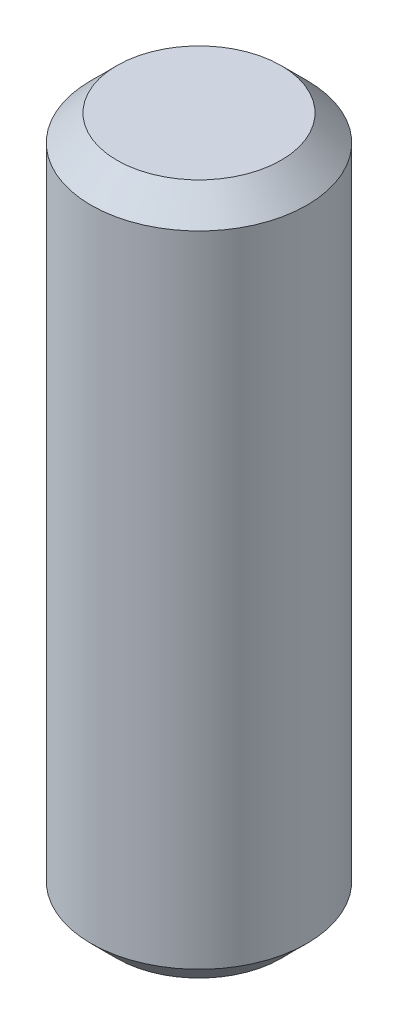
from build123d import *

# Parameters (mm, degrees)
SKETCH2_R           = 6.35
BOSS_EXTRUDE1_DEPTH = 40.64
CHAMFER1_SIZE       = 1.524


with BuildPart() as part:
    # Sketch2 → Boss-Extrude1 (new body)
    with BuildSketch(Plane(origin=(0, 0, 0), x_dir=(1, 0, 0), z_dir=(0, 1, 0))):
        Circle(SKETCH2_R)
    extrude(amount=BOSS_EXTRUDE1_DEPTH)

    # Chamfer1
    chamfer1_edges = [part.edges().sort_by_distance(p)[0] for p in [
        (-6.35, 0, 0),
        (-6.35, 40.64, 0),
    ]]
    chamfer(chamfer1_edges, length=CHAMFER1_SIZE)


solid = part.part
